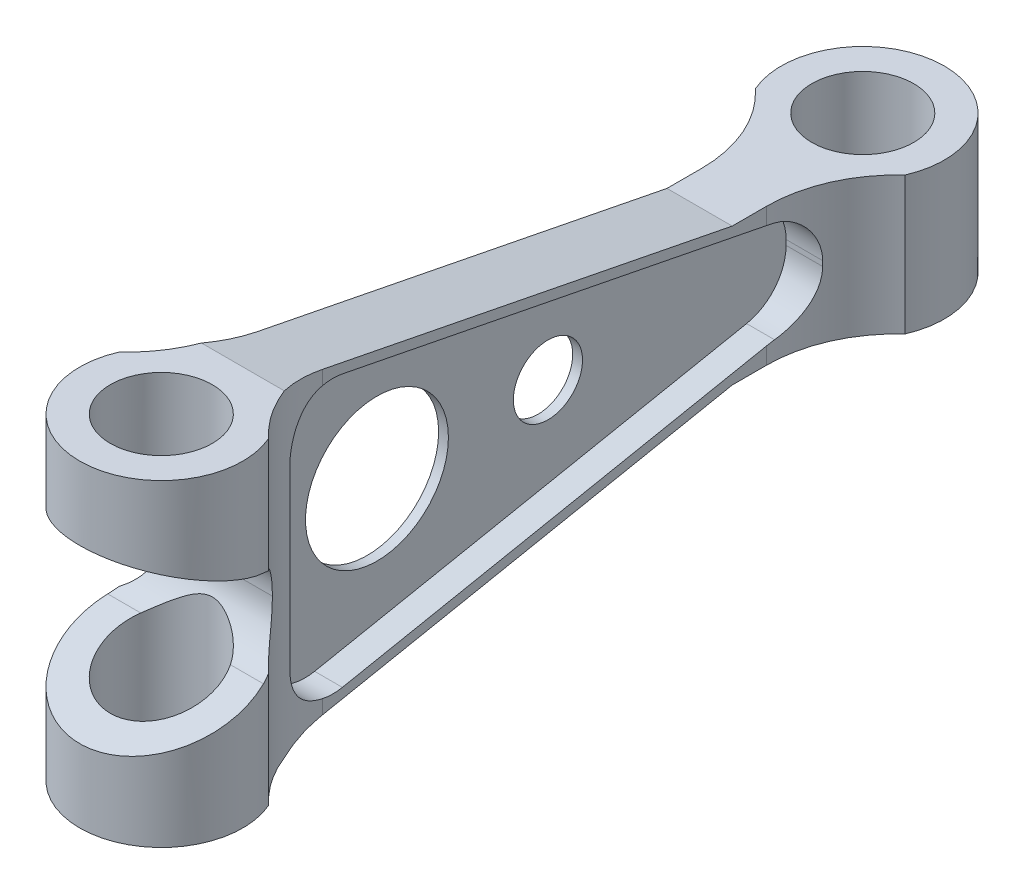
from build123d import *

# Parameters (mm, degrees)
SKETCH2_R               = 19.84375
BOSS_EXTRUDE1_DEPTH     = 123.698
SKETCH3_R               = 19.05
CUT_EXTRUDE1_DEPTH      = 331.472839586
CUT_EXTRUDE1_DEPTH_BACK = 331.472839586
CUT_EXTRUDE2_START      = -10.795
CUT_EXTRUDE2_DEPTH      = 343.728785262


with BuildPart() as part:
    # Sketch2 → Boss-Extrude1 (new body)
    with BuildSketch(Plane(origin=(0, 0, 0), x_dir=(1, 0, 0), z_dir=(0, 1, 0))):
        with BuildLine():
            Line((-12.7, -50.079615691), (-12.7, -222.970384309))
            ThreePointArc((-12.7, -222.970384309), (-16.980150837, -243.379784933), (-29.099355663, -260.35))
            ThreePointArc((-29.099355663, -260.35), (0, -304.8), (29.099355663, -260.35))
            ThreePointArc((29.099355663, -260.35), (16.980150837, -243.379784933), (12.7, -222.970384309))
            Line((12.7, -222.970384309), (12.7, -50.079615691))
            ThreePointArc((12.7, -50.079615691), (16.980150837, -29.670215067), (29.099355663, -12.7))
            ThreePointArc((29.099355663, -12.7), (0, 31.75), (-29.099355663, -12.7))
            ThreePointArc((-29.099355663, -12.7), (-16.980150837, -29.670215067), (-12.7, -50.079615691))
        make_face()
        with Locations(Location((0, -273.05, 0), (0, 0, 270))):
            Circle(SKETCH2_R, mode=Mode.SUBTRACT)
        with Locations(Location((0, 0, 0), (0, 0, 270))):
            Circle(SKETCH2_R, mode=Mode.SUBTRACT)
    extrude(amount=BOSS_EXTRUDE1_DEPTH)

    # Sketch3 → Cut-Extrude1 (cut, two sides)
    with BuildSketch(Plane(origin=(0, 0, 0), x_dir=(0, 0, -1), z_dir=(1, 0, 0))) as cut_extrude1_sk:
        with BuildLine():
            Line((-289.037979654, 61.849), (-250.966020346, 61.849))
            ThreePointArc((-250.966020346, 61.849), (-270.002, 80.168261599), (-289.037979654, 61.849))
        make_face()
        with BuildLine():
            ThreePointArc((-289.037979654, 61.849), (-270.002, 43.529738401), (-250.966020346, 61.849))
            Line((-250.966020346, 61.849), (-289.037979654, 61.849))
        make_face()
        with Locations((-270.002, 61.118261599)):
            Circle(SKETCH3_R)
        with Locations((-270.002, 62.579738401)):
            Circle(SKETCH3_R)
        with BuildLine():
            ThreePointArc((-263.589413096, 43.18), (-281.270114367, 45.758180264), (-289.037979654, 61.849))
            Line((-289.037979654, 61.849), (-304.8, 61.849))
            Line((-304.8, 61.849), (-304.8, 28.448))
            Line((-304.8, 28.448), (-263.589413096, 43.18))
        make_face()
        with BuildLine():
            ThreePointArc((-289.037979654, 61.849), (-281.270114367, 77.939819736), (-263.589413096, 80.518))
            Line((-263.589413096, 80.518), (-304.8, 95.25))
            Line((-304.8, 95.25), (-304.8, 61.849))
            Line((-304.8, 61.849), (-289.037979654, 61.849))
        make_face()
        with BuildLine():
            ThreePointArc((-163.195, 61.849), (-191.008, 89.662), (-218.821, 61.849))
            Line((-218.821, 61.849), (-163.195, 61.849))
        make_face()
        with BuildLine():
            Line((-163.195, 61.849), (-218.821, 61.849))
            ThreePointArc((-218.821, 61.849), (-191.008, 34.036), (-163.195, 61.849))
        make_face()
        Polygon((31.75, 88.646), (-63.5, 88.646), (-241.3, 123.698), (31.75, 123.698), align=None)
        Polygon((31.75, 0), (31.75, 35.052), (-63.5, 35.052), (-241.3, 0), align=None)
        with BuildLine():
            ThreePointArc((-110.998, 61.849), (-124.46, 75.311), (-137.922, 61.849))
            Line((-137.922, 61.849), (-110.998, 61.849))
        make_face()
        with BuildLine():
            Line((-110.998, 61.849), (-137.922, 61.849))
            ThreePointArc((-137.922, 61.849), (-124.46, 48.387), (-110.998, 61.849))
        make_face()
    extrude(amount=CUT_EXTRUDE1_DEPTH, mode=Mode.SUBTRACT)
    extrude(cut_extrude1_sk.sketch, amount=-CUT_EXTRUDE1_DEPTH_BACK, mode=Mode.SUBTRACT)

    # Sketch4 → Cut-Extrude2 (cut)
    with BuildSketch(Plane(origin=(12.7, 0, 0), x_dir=(0, 0, -1), z_dir=(1, 0, 0)).offset(CUT_EXTRUDE2_START)):
        with BuildLine():
            Line((-50.079615691, 82.116934418), (-215.26334861, 114.681727479))
            ThreePointArc((-215.26334861, 114.681727479), (-219.120431461, 115.040686403), (-222.970384309, 114.611964231))
            Line((-222.970384309, 114.611964231), (-222.970384309, 61.849))
            Line((-222.970384309, 61.849), (-218.821, 61.849))
            ThreePointArc((-218.821, 61.849), (-191.008, 89.662), (-163.195, 61.849))
            Line((-163.195, 61.849), (-137.922, 61.849))
            ThreePointArc((-137.922, 61.849), (-124.46, 75.311), (-110.998, 61.849))
            Line((-110.998, 61.849), (-50.079615691, 61.849))
            Line((-50.079615691, 61.849), (-50.079615691, 82.116934418))
        make_face()
        with BuildLine():
            Line((-222.970384309, 61.849), (-222.970384309, 114.611964231))
            ThreePointArc((-222.970384309, 114.611964231), (-233.772454814, 107.955497873), (-237.998, 95.991466803))
            Line((-237.998, 95.991466803), (-237.998, 61.849))
            Line((-237.998, 61.849), (-222.970384309, 61.849))
        make_face()
        with BuildLine():
            Line((-222.970384309, 9.086035769), (-222.970384309, 61.849))
            Line((-222.970384309, 61.849), (-237.998, 61.849))
            Line((-237.998, 61.849), (-237.998, 27.706533197))
            ThreePointArc((-237.998, 27.706533197), (-233.772454814, 15.742502127), (-222.970384309, 9.086035769))
        make_face()
        with BuildLine():
            Line((-50.079615691, 41.581065582), (-50.079615691, 61.849))
            Line((-50.079615691, 61.849), (-110.998, 61.849))
            ThreePointArc((-110.998, 61.849), (-124.46, 48.387), (-137.922, 61.849))
            Line((-137.922, 61.849), (-163.195, 61.849))
            ThreePointArc((-163.195, 61.849), (-191.008, 34.036), (-218.821, 61.849))
            Line((-218.821, 61.849), (-222.970384309, 61.849))
            Line((-222.970384309, 61.849), (-222.970384309, 9.086035769))
            ThreePointArc((-222.970384309, 9.086035769), (-219.120431461, 8.657313597), (-215.26334861, 9.016272521))
            Line((-215.26334861, 9.016272521), (-50.079615691, 41.581065582))
        make_face()
        with BuildLine():
            Line((-31.75, 61.849), (-50.079615691, 61.849))
            Line((-50.079615691, 61.849), (-50.079615691, 41.581065582))
            Line((-50.079615691, 41.581065582), (-47.11534861, 42.165449664))
            ThreePointArc((-47.11534861, 42.165449664), (-36.084445152, 48.757985533), (-31.75, 60.85571034))
            Line((-31.75, 60.85571034), (-31.75, 61.849))
        make_face()
        with BuildLine():
            Line((-47.11534861, 81.532550336), (-50.079615691, 82.116934418))
            Line((-50.079615691, 82.116934418), (-50.079615691, 61.849))
            Line((-50.079615691, 61.849), (-31.75, 61.849))
            Line((-31.75, 61.849), (-31.75, 62.84228966))
            ThreePointArc((-31.75, 62.84228966), (-36.084445152, 74.940014467), (-47.11534861, 81.532550336))
        make_face()
    cut_extrude2 = extrude(amount=CUT_EXTRUDE2_DEPTH, mode=Mode.SUBTRACT)

    # Mirror1: Cut-Extrude2 across plane
    add(cut_extrude2.mirror(Plane(origin=(0, 0, 0), x_dir=(0, 0, 1), z_dir=(1, 0, 0))), mode=Mode.SUBTRACT)


solid = part.part
